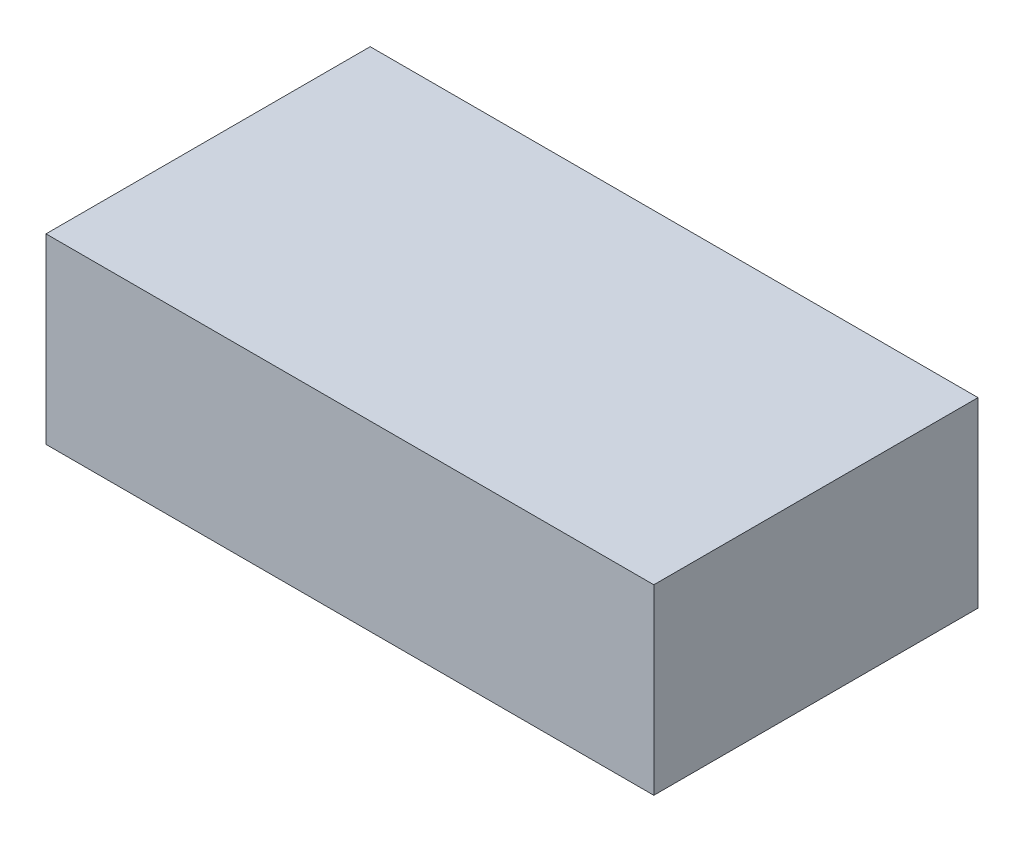
from build123d import *

# Parameters (mm, degrees)
SKETCH_1_W          = 150
SKETCH_1_H          = 80
EXTRUDE_1_DEPTH     = 45
SKETCH_2_R          = 32.5
SKETCH_2_R_2        = 20.5
CUT_EXTRUDE_1_DEPTH = 1.5


with BuildPart() as part:
    # 草图1 → 凸台-拉伸1 (new body)
    with BuildSketch(Plane(origin=(0, 0, 0), x_dir=(1, 0, 0), z_dir=(0, 1, 0))):
        Rectangle(SKETCH_1_W, SKETCH_1_H)
    extrude(amount=EXTRUDE_1_DEPTH)

    # 草图2 → 切除-拉伸1 (cut)
    with BuildSketch(Plane.XZ):
        with Locations((38, 0)):
            Circle(SKETCH_2_R)
        with Locations((38, 0)):
            Circle(SKETCH_2_R_2, mode=Mode.SUBTRACT)
        with Locations((-38, 0)):
            Circle(SKETCH_2_R)
        with Locations((-38, 0)):
            Circle(SKETCH_2_R_2, mode=Mode.SUBTRACT)
    extrude(amount=-CUT_EXTRUDE_1_DEPTH, mode=Mode.SUBTRACT)


solid = part.part
